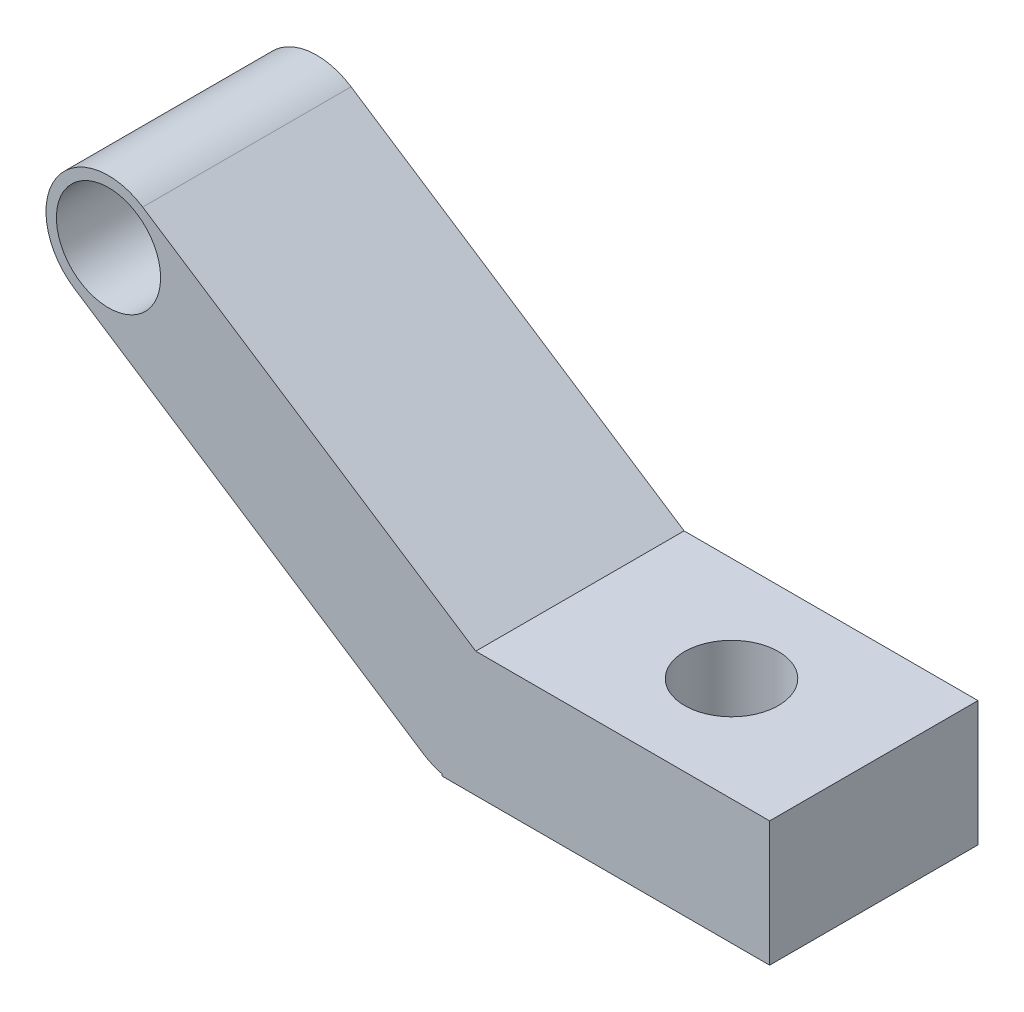
from build123d import *

# Parameters (mm, degrees)
SKETCH2_R           = 50
BOSS_EXTRUDE1_DEPTH = 200
SKETCH4_W           = 314.300936027
SKETCH4_H           = 120
BOSS_EXTRUDE2_DEPTH = 200
SKETCH7_R           = 45
CUT_EXTRUDE1_DEPTH  = 121


with BuildPart() as part:
    # Sketch2 → Boss-Extrude1 (new body)
    with BuildSketch(Plane.XY):
        with BuildLine():
            Line((-32.872426913, -50.193660445), (-367.496829879, 168.955852308))
            ThreePointArc((-367.496829879, 168.955852308), (-384.818063411, 252.021939666), (-301.751976053, 269.343173198))
            Line((-301.751976053, 269.343173198), (32.872426913, 50.193660445))
            ThreePointArc((32.872426913, 50.193660445), (50.193660445, -32.872426913), (-32.872426913, -50.193660445))
        make_face()
        with Locations((-334.624402966, 219.149512753)):
            Circle(SKETCH2_R, mode=Mode.SUBTRACT)
    extrude(amount=BOSS_EXTRUDE1_DEPTH)

    # Sketch4 → Boss-Extrude2 (add)
    with BuildSketch(Plane.XY.offset(200)):
        with Locations((142.849531987, 0)):
            Rectangle(SKETCH4_W, SKETCH4_H)
    extrude(amount=-BOSS_EXTRUDE2_DEPTH)

    # Sketch7 → Cut-Extrude1 (cut, through all)
    with BuildSketch(Plane(origin=(0, 60, 0), x_dir=(1, 0, 0), z_dir=(0, 1, 0))):
        with Locations((163.399277188, -100)):
            Circle(SKETCH7_R)
    extrude(amount=-CUT_EXTRUDE1_DEPTH, mode=Mode.SUBTRACT)


solid = part.part
